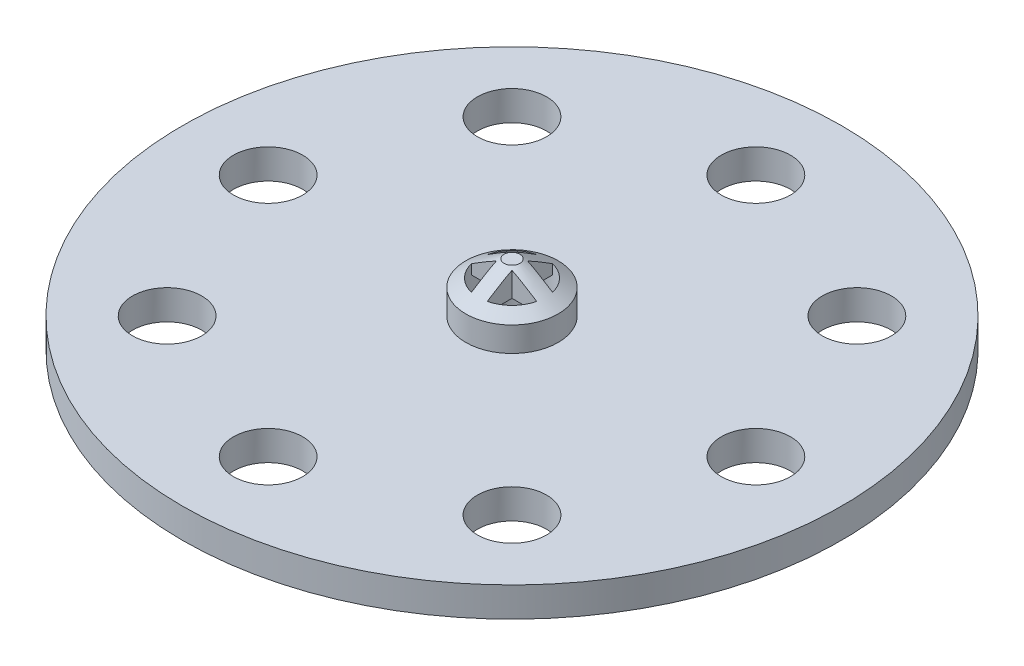
from build123d import *

# Parameters (mm, degrees)
SKETCH1_R               = 25
BOSS_EXTRUDE1_DEPTH     = 3.5
SKETCH3_R               = 8.75
BOSS_EXTRUDE2_DEPTH     = 4
SKETCH4_R               = 2.625
CUT_EXTRUDE1_DEPTH      = 3.5
CUT_EXTRUDE2_DEPTH      = 10
CUT_EXTRUDE3_DEPTH      = 26
CUT_EXTRUDE3_DEPTH_BACK = 26
CUT_EXTRUDE4_DEPTH      = 26
CUT_EXTRUDE4_DEPTH_BACK = 26
SKETCH11_R              = 25
CUT_EXTRUDE5_DEPTH      = 3
BOSS_EXTRUDE3_DEPTH     = 3
SKETCH13_R              = 8.75
SKETCH13_R_2            = 2.55
BOSS_EXTRUDE4_DEPTH     = 3
SKETCH16_R              = 25
SKETCH16_R_2            = 2.625
BOSS_EXTRUDE5_DEPTH     = 2.5
SKETCH17_R              = 25
SKETCH17_R_2            = 8.75
CUT_EXTRUDE6_DEPTH      = 0.75
CUT_EXTRUDE7_DEPTH      = 1
SKETCH19_R              = 8.75
SKETCH19_R_2            = 3.5
CUT_EXTRUDE8_DEPTH      = 20
SKETCH20_R              = 6.415433717
CUT_EXTRUDE9_DEPTH      = 10
SKETCH22_R              = 3.5
CUT_EXTRUDE10_DEPTH     = 0.5


with BuildPart() as part:
    # Sketch1 → Boss-Extrude1 (new body)
    with BuildSketch(Plane(origin=(0, 0, 0), x_dir=(1, 0, 0), z_dir=(0, 1, 0))):
        Circle(SKETCH1_R)
    extrude(amount=BOSS_EXTRUDE1_DEPTH)

    # Sketch3 → Boss-Extrude2 (add)
    with BuildSketch(Plane(origin=(0, 3.5, 0), x_dir=(1, 0, 0), z_dir=(0, 1, 0))):
        Circle(SKETCH3_R)
    extrude(amount=BOSS_EXTRUDE2_DEPTH)

    # Sketch4 → Cut-Extrude1 (cut)
    with BuildSketch(Plane(origin=(0, 3.5, 0), x_dir=(1, 0, 0), z_dir=(0, 1, 0))):
        with Locations((0, 18.5)):
            Circle(SKETCH4_R)
        with Locations((13.081475452, 13.081475452)):
            Circle(SKETCH4_R)
        with Locations((18.5, 0)):
            Circle(SKETCH4_R)
        with Locations((13.081475452, -13.081475452)):
            Circle(SKETCH4_R)
        with Locations((0, -18.5)):
            Circle(SKETCH4_R)
        with Locations((-13.081475452, -13.081475452)):
            Circle(SKETCH4_R)
        with Locations((-18.5, 0)):
            Circle(SKETCH4_R)
        with Locations((-13.081475452, 13.081475452)):
            Circle(SKETCH4_R)
    extrude(amount=-CUT_EXTRUDE1_DEPTH, mode=Mode.SUBTRACT)

    # Sketch7 → Cut-Extrude2 (cut)
    with BuildSketch(Plane.XZ):
        with BuildLine():
            Line((1.9, 1.700735135), (1.9, -1.700735135))
            ThreePointArc((1.9, -1.700735135), (-2.55, 0), (1.9, 1.700735135))
        make_face()
    extrude(amount=-CUT_EXTRUDE2_DEPTH, mode=Mode.SUBTRACT)

    # Sketch8 → Cut-Extrude3 (cut, two sides)
    with BuildSketch(Plane(origin=(0, 0, 0), x_dir=(0, 0, -1), z_dir=(1, 0, 0))) as cut_extrude3_sk:
        with BuildLine():
            Line((-2.5, 6), (2.5, 6))
            ThreePointArc((2.5, 6), (3.5, 5), (2.5, 4))
            Line((2.5, 4), (-2.5, 4))
            ThreePointArc((-2.5, 4), (-3.5, 5), (-2.5, 6))
        make_face()
    extrude(amount=CUT_EXTRUDE3_DEPTH, mode=Mode.SUBTRACT)
    extrude(cut_extrude3_sk.sketch, amount=-CUT_EXTRUDE3_DEPTH_BACK, mode=Mode.SUBTRACT)

    # Sketch9 → Cut-Extrude4 (cut, two sides)
    with BuildSketch(Plane.XY) as cut_extrude4_sk:
        with BuildLine():
            Line((-2.5, 6), (2.5, 6))
            ThreePointArc((2.5, 6), (3.5, 5), (2.5, 4))
            Line((2.5, 4), (-2.5, 4))
            ThreePointArc((-2.5, 4), (-3.5, 5), (-2.5, 6))
        make_face()
    extrude(amount=CUT_EXTRUDE4_DEPTH, mode=Mode.SUBTRACT)
    extrude(cut_extrude4_sk.sketch, amount=-CUT_EXTRUDE4_DEPTH_BACK, mode=Mode.SUBTRACT)

    # Sketch11 → Cut-Extrude5 (cut)
    with BuildSketch(Plane(origin=(0, 3.5, 0), x_dir=(1, 0, 0), z_dir=(0, 1, 0))):
        Circle(SKETCH11_R)
    extrude(amount=-CUT_EXTRUDE5_DEPTH, mode=Mode.SUBTRACT)

    # Sketch12 → Boss-Extrude3 (add)
    with BuildSketch(Plane(origin=(0, 0.5, 0), x_dir=(1, 0, 0), z_dir=(0, 1, 0))):
        Polygon((0.6, 0.6), (5, 0.6), (5, -0.6), (0.6, -0.6), (0.6, -5), (-0.6, -5), (-0.6, -0.6), (-5, -0.6), (-5, 0.6), (-0.6, 0.6), (-0.6, 5), (0.6, 5), align=None)
    extrude(amount=BOSS_EXTRUDE3_DEPTH)

    # Sketch13 → Boss-Extrude4 (add)
    with BuildSketch(Plane(origin=(0, 0.5, 0), x_dir=(1, 0, 0), z_dir=(0, 1, 0))):
        Circle(SKETCH13_R)
        Circle(SKETCH13_R_2, mode=Mode.SUBTRACT)
    extrude(amount=BOSS_EXTRUDE4_DEPTH)

    # Sketch15 → Revolve1 (revolve)
    with BuildSketch(Plane.XY):
        Polygon((0, 13.5), (-8.75, 7.5), (0, 7.5), align=None)
    revolve(axis=Axis((0, -5.481339273, 0), (0, 1, 0)))

    # Sketch16 → Boss-Extrude5 (add)
    with BuildSketch(Plane.XZ):
        Circle(SKETCH16_R)
        with Locations((13.081475452, 13.081475452)):
            Circle(SKETCH16_R_2, mode=Mode.SUBTRACT)
        with Locations((0, 18.5)):
            Circle(SKETCH16_R_2, mode=Mode.SUBTRACT)
        with Locations((-13.081475452, 13.081475452)):
            Circle(SKETCH16_R_2, mode=Mode.SUBTRACT)
        with Locations((-18.5, 0)):
            Circle(SKETCH16_R_2, mode=Mode.SUBTRACT)
        with Locations((-13.081475452, -13.081475452)):
            Circle(SKETCH16_R_2, mode=Mode.SUBTRACT)
        with Locations((0, -18.5)):
            Circle(SKETCH16_R_2, mode=Mode.SUBTRACT)
        with Locations((13.081475452, -13.081475452)):
            Circle(SKETCH16_R_2, mode=Mode.SUBTRACT)
        with Locations((18.5, 0)):
            Circle(SKETCH16_R_2, mode=Mode.SUBTRACT)
        with BuildLine():
            Line((1.9, 1.700735135), (1.9, -1.700735135))
            ThreePointArc((1.9, -1.700735135), (-2.55, 0), (1.9, 1.700735135))
        make_face(mode=Mode.SUBTRACT)
    extrude(amount=BOSS_EXTRUDE5_DEPTH)

    # Sketch17 → Cut-Extrude6 (cut)
    with BuildSketch(Plane(origin=(0, 0.5, 0), x_dir=(1, 0, 0), z_dir=(0, 1, 0))):
        Circle(SKETCH17_R)
        Circle(SKETCH17_R_2, mode=Mode.SUBTRACT)
    extrude(amount=-CUT_EXTRUDE6_DEPTH, mode=Mode.SUBTRACT)

    # Sketch18 → Cut-Extrude7 (cut)
    with BuildSketch(Plane.XZ.offset(-0.5)):
        with BuildLine():
            Line((1.9, 1.700735135), (1.9, -1.700735135))
            ThreePointArc((1.9, -1.700735135), (-2.55, 0), (1.9, 1.700735135))
        make_face()
    extrude(amount=-CUT_EXTRUDE7_DEPTH, mode=Mode.SUBTRACT)

    # Sketch19 → Cut-Extrude8 (cut)
    with BuildSketch(Plane(origin=(0, -0.25, 0), x_dir=(1, 0, 0), z_dir=(0, 1, 0))):
        Circle(SKETCH19_R)
        Circle(SKETCH19_R_2, mode=Mode.SUBTRACT)
    extrude(amount=CUT_EXTRUDE8_DEPTH, mode=Mode.SUBTRACT)

    # Sketch20 → Cut-Extrude9 (cut)
    with BuildSketch(Plane.XZ.offset(-6)):
        Circle(SKETCH20_R)
    extrude(amount=-CUT_EXTRUDE9_DEPTH, mode=Mode.SUBTRACT)

    # Sketch22 → Cut-Extrude10 (cut)
    with BuildSketch(Plane(origin=(0, 4, 0), x_dir=(1, 0, 0), z_dir=(0, 1, 0))):
        Circle(SKETCH22_R)
    extrude(amount=-CUT_EXTRUDE10_DEPTH, mode=Mode.SUBTRACT)

    # Sketch23 → Cut-Revolve3 (revolve, cut)
    with BuildSketch(Plane(origin=(0, 0, 0), x_dir=(0, 0, -1), z_dir=(1, 0, 0))):
        Polygon((3.5, 1.625), (0.6, 3.5), (3.5, 3.5), align=None)
    revolve(axis=Axis((0, -5.481339273, 0), (0, 1, 0)), mode=Mode.SUBTRACT)


solid = part.part
